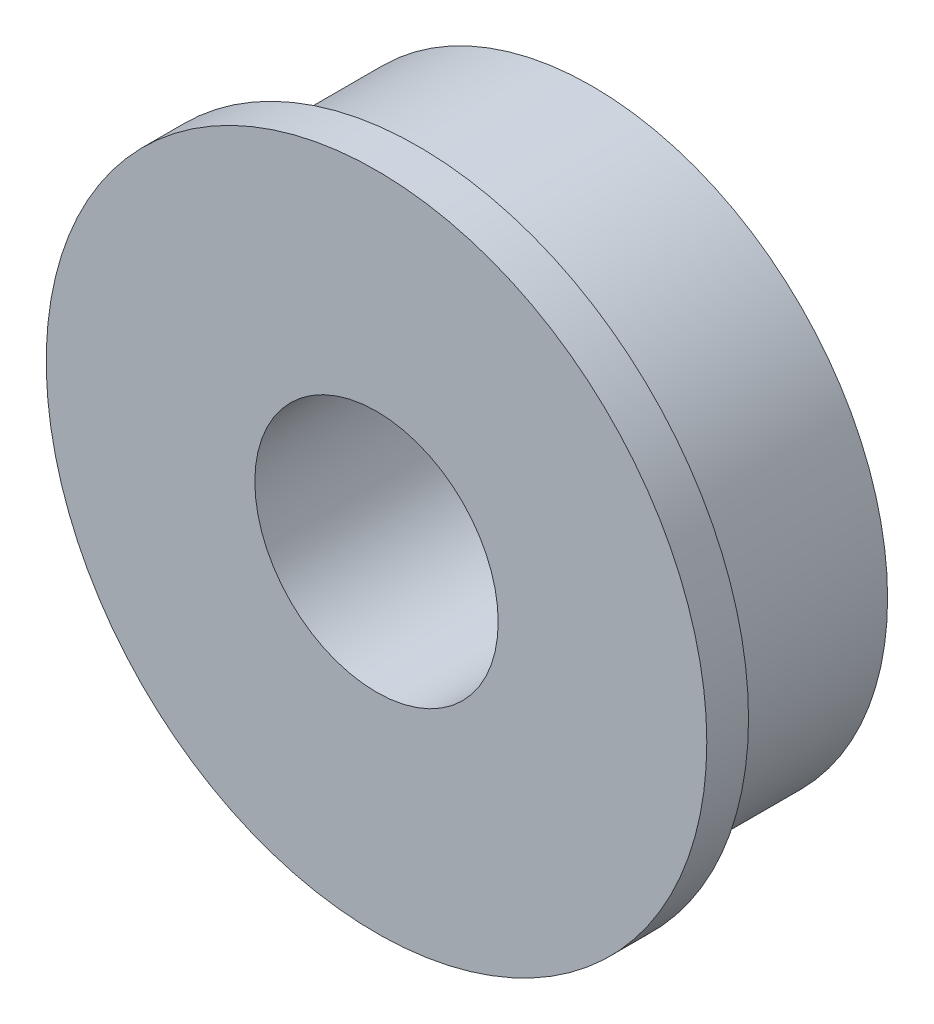
from build123d import *

# Parameters (mm, degrees)
SKETCH_1_R          = 8.5
EXTRUDE_1_DEPTH     = 5
SKETCH_2_R          = 9.5
EXTRUDE_2_DEPTH     = 1.2
CUT_EXTRUDE_1_REACH = 8.2
SKETCH_3_R          = 3.5


with BuildPart() as part:
    # 草圖1 → 填料-伸長1 (new body)
    with BuildSketch(Plane.XY):
        Circle(SKETCH_1_R)
    extrude(amount=EXTRUDE_1_DEPTH)

    # 草圖2 → 填料-伸長2 (add)
    with BuildSketch(Plane.XY.offset(5)):
        Circle(SKETCH_2_R)
    extrude(amount=EXTRUDE_2_DEPTH)

    # 草圖3 → 除料-伸長1 (cut, up to next)
    with BuildSketch(Plane.XY.offset(6.2), mode=Mode.PRIVATE) as cut_extrude_1_sk1:
        Circle(SKETCH_3_R)
    cut_extrude_1_tool1 = extrude(cut_extrude_1_sk1.sketch, amount=-CUT_EXTRUDE_1_REACH, mode=Mode.PRIVATE) & part.part
    add(cut_extrude_1_tool1.solids().sort_by_distance((0, 0, 6.2))[0], mode=Mode.SUBTRACT)


solid = part.part
